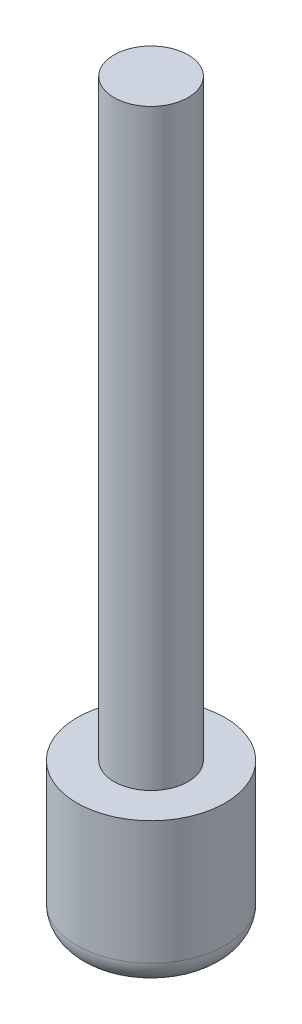
from build123d import *


with BuildPart() as part:
    # Sketch1 → Revolve1 (revolve)
    with BuildSketch(Plane.XY):
        with BuildLine():
            Line((0, 0), (50.8, 0))
            ThreePointArc((50.8, 0), (68.760512242, 7.439487758), (76.2, 25.4))
            Line((76.2, 25.4), (76.2, 152.4))
            Line((76.2, 152.4), (38.1, 152.4))
            Line((38.1, 152.4), (38.1, 762))
            Line((38.1, 762), (0, 762))
            Line((0, 762), (0, 152.4))
            Line((0, 152.4), (0, 0))
        make_face()
    revolve(axis=Axis((0, 152.4, 0), (0, 1, 0)))


solid = part.part
